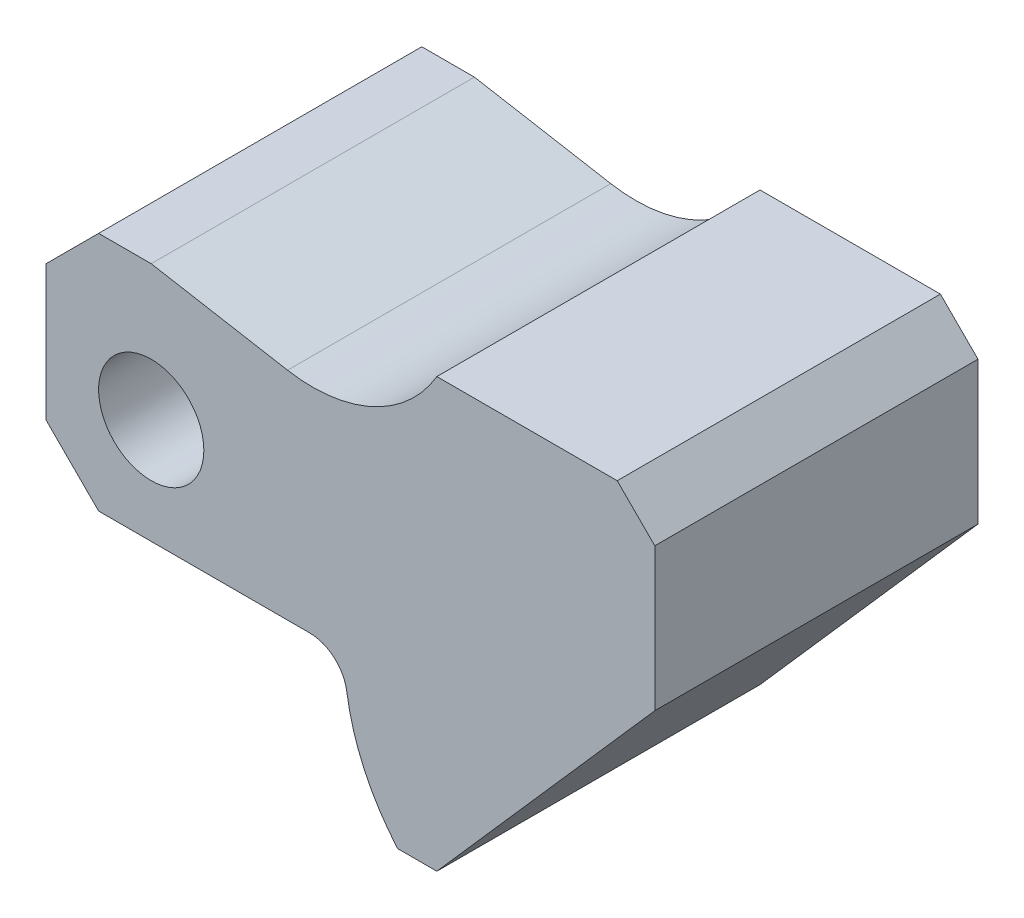
from build123d import *

# Parameters (mm, degrees)
ESQUISSE2_R        = 7
BOSS_EXTRU_2_DEPTH = 21.5


with BuildPart() as part:
    # Esquisse2 → Boss.-Extru.2 (new body, symmetric)
    with BuildSketch(Plane.XY):
        with BuildLine():
            Line((46.788067397, -19), (52, -19))
            Line((52, -19), (81, 14))
            Line((81, 14), (81, 33))
            Line((81, 33), (76, 38))
            Line((76, 38), (52, 38))
            ThreePointArc((52, 38), (43.513473837, 30.283893076), (32.139737934, 28.801474779))
            Line((32.139737934, 28.801474779), (14, 32))
            Line((14, 32), (7, 32))
            Line((7, 32), (0, 25))
            Line((0, 25), (0, 7))
            Line((0, 7), (7, 0))
            Line((7, 0), (35.066626255, 0))
            ThreePointArc((35.066626255, 0), (38.331862036, -1.213413768), (40.012264997, -4.264705882))
            ThreePointArc((40.012264997, -4.264705882), (42.3490952, -12.115672061), (46.788067397, -19))
        make_face()
        with Locations((14, 14)):
            Circle(ESQUISSE2_R, mode=Mode.SUBTRACT)
    extrude(amount=BOSS_EXTRU_2_DEPTH, both=True)


solid = part.part
